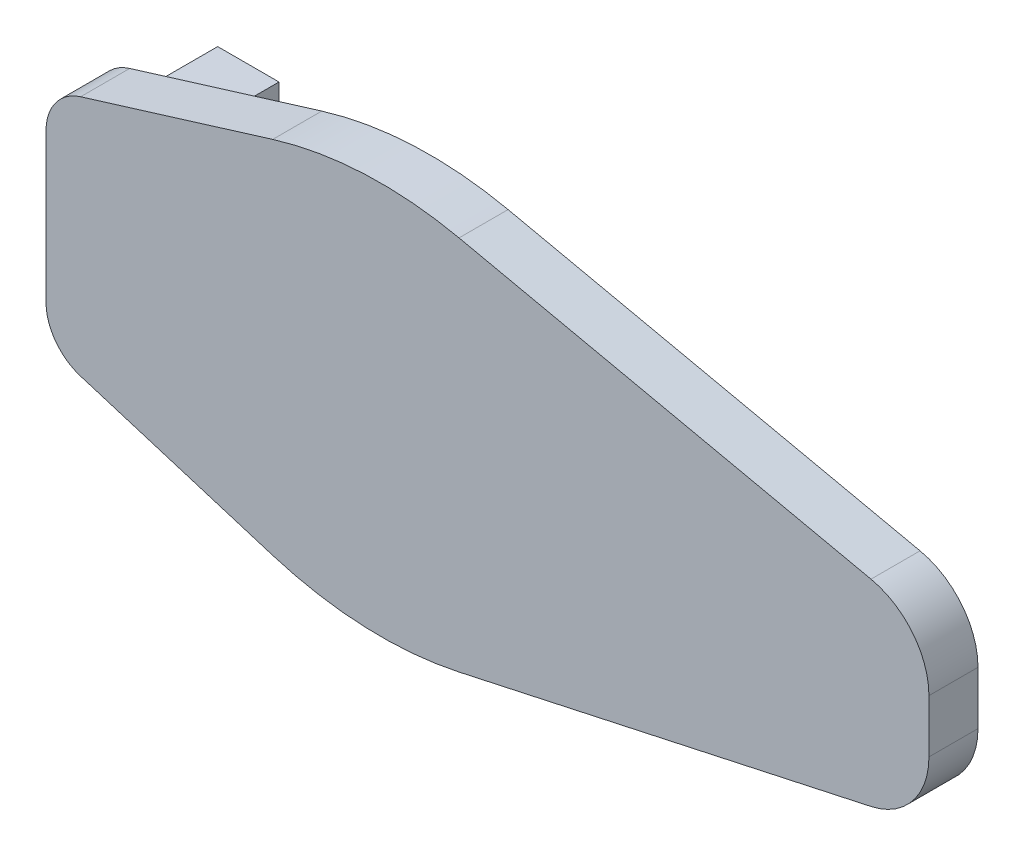
from build123d import *

# Parameters (mm, degrees)
BOSS_EXTRUDE1_DEPTH = 4
SKETCH2_W           = 5
SKETCH2_H           = 10
BOSS_EXTRUDE2_DEPTH = 10
CUT_EXTRUDE1_REACH  = 7
SKETCH3_R           = 1.55


with BuildPart() as part:
    # Sketch1 → Boss-Extrude1 (new body)
    with BuildSketch(Plane.XY):
        with BuildLine():
            Line((2.823656605, 9.868817417), (18.486372689, 14.688114674))
            ThreePointArc((18.486372689, 14.688114674), (26.042750669, 15.988011567), (33.681837484, 15.33003533))
            Line((33.681837484, 15.33003533), (67.274577866, 8.027265681))
            ThreePointArc((67.274577866, 8.027265681), (70.67158791, 5.929345796), (72, 2.164207498))
            Line((72, 2.164207498), (72, -2.164207498))
            ThreePointArc((72, -2.164207498), (70.67158791, -5.929345796), (67.274577866, -8.027265681))
            Line((67.274577866, -8.027265681), (33.681837484, -15.33003533))
            ThreePointArc((33.681837484, -15.33003533), (26.042750669, -15.988011567), (18.486372689, -14.688114674))
            Line((18.486372689, -14.688114674), (2.823656605, -9.868817417))
            ThreePointArc((2.823656605, -9.868817417), (0.782440864, -8.422109009), (0, -6.045701382))
            Line((0, -6.045701382), (0, 6.045701382))
            ThreePointArc((0, 6.045701382), (0.782440864, 8.422109009), (2.823656605, 9.868817417))
        make_face()
    extrude(amount=BOSS_EXTRUDE1_DEPTH)

    # Sketch2 → Boss-Extrude2 (add)
    with BuildSketch(Plane(origin=(0, 0, 0), x_dir=(-1, 0, 0), z_dir=(0, 0, -1))):
        with Locations((-2.5, 0)):
            Rectangle(SKETCH2_W, SKETCH2_H)
    extrude(amount=BOSS_EXTRUDE2_DEPTH)

    # Sketch3 → Cut-Extrude1 (cut, up to next)
    with BuildSketch(Plane(origin=(5, 0, 0), x_dir=(0, 0, -1), z_dir=(1, 0, 0)), mode=Mode.PRIVATE) as cut_extrude1_sk1:
        with Locations((5, 0)):
            Circle(SKETCH3_R)
    cut_extrude1_tool1 = extrude(cut_extrude1_sk1.sketch, amount=-CUT_EXTRUDE1_REACH, mode=Mode.PRIVATE) & part.part
    add(cut_extrude1_tool1.solids().sort_by_distance((5, 0, -5))[0], mode=Mode.SUBTRACT)


solid = part.part
